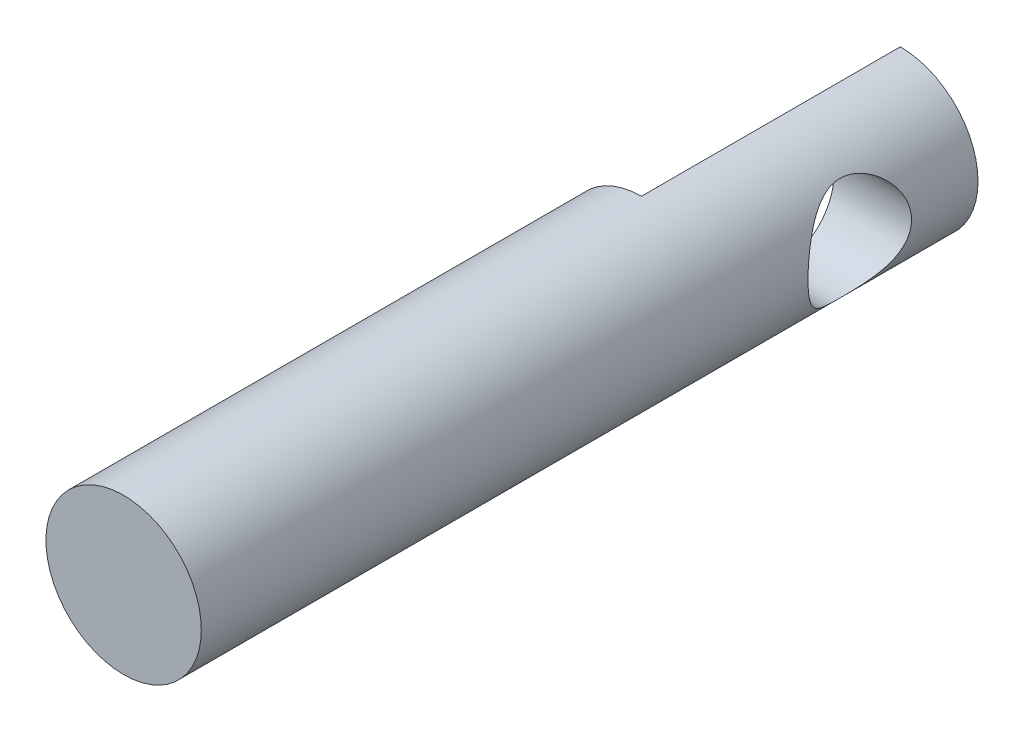
from build123d import *

# Parameters (mm, degrees)
SKETCH1_R           = 1.5
BOSS_EXTRUDE1_DEPTH = 15
SKETCH2_W           = 5
SKETCH2_H           = 4.697023624
CUT_EXTRUDE1_DEPTH  = 30
SKETCH3_R           = 1
CUT_EXTRUDE2_DEPTH  = 30


with BuildPart() as part:
    # Sketch1 → Boss-Extrude1 (new body)
    with BuildSketch(Plane.XY):
        Circle(SKETCH1_R)
    extrude(amount=BOSS_EXTRUDE1_DEPTH)

    # Sketch2 → Cut-Extrude1 (cut)
    with BuildSketch(Plane(origin=(0, 0, 0), x_dir=(0, 0, -1), z_dir=(1, 0, 0))):
        with Locations((-2.5, -0.042086347)):
            Rectangle(SKETCH2_W, SKETCH2_H)
    extrude(amount=-CUT_EXTRUDE1_DEPTH, mode=Mode.SUBTRACT)

    # Sketch3 → Cut-Extrude2 (cut)
    with BuildSketch(Plane.ZY):
        with Locations((2.282543491, 0)):
            Circle(SKETCH3_R)
    extrude(amount=-CUT_EXTRUDE2_DEPTH, mode=Mode.SUBTRACT)


solid = part.part
